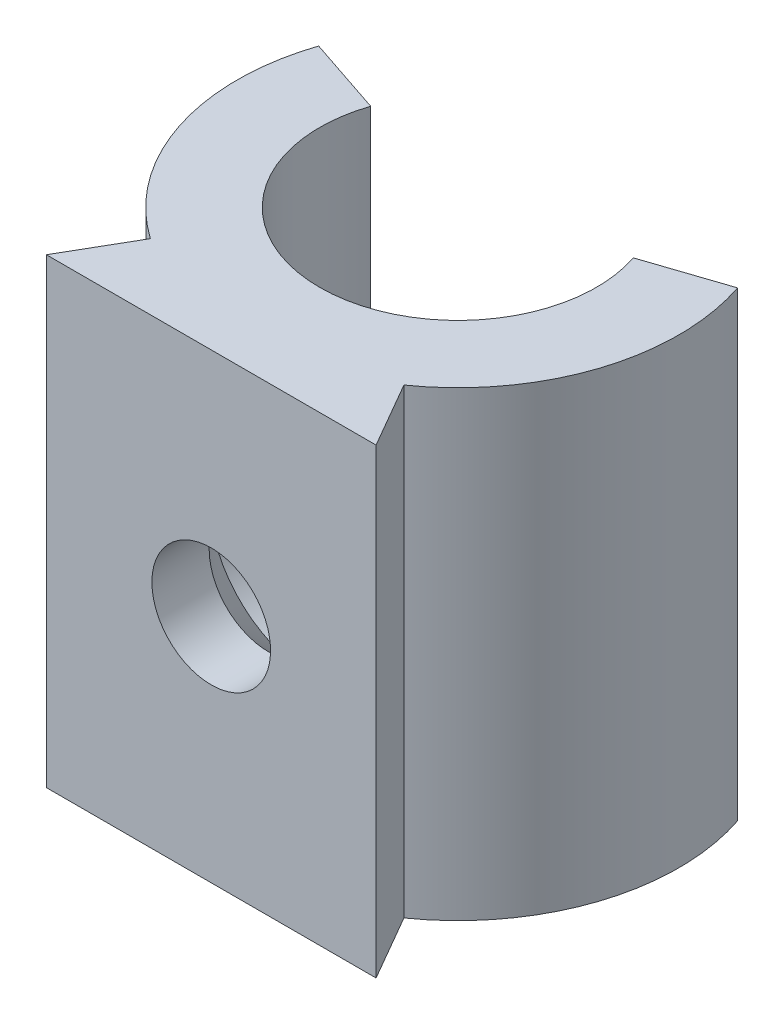
from build123d import *

# Parameters (mm, degrees)
BOSS_EXTRUDE1_DEPTH                             = 14
CUT_EXTRUDE1_DEPTH                              = 17.760296299
CUT_EXTRUDE1_DEPTH_BACK                         = 0.2
SKETCH4_R                                       = 3.25
CSK_FOR_M3_FLAT_HEAD_MACHINE_SCREW4_D           = 3.6
CSK_FOR_M3_FLAT_HEAD_MACHINE_SCREW4_DEPTH       = 7.5
CSK_FOR_M3_FLAT_HEAD_MACHINE_SCREW4_CSINK_D     = 6.3
CSK_FOR_M3_FLAT_HEAD_MACHINE_SCREW4_CSINK_ANGLE = 90
CSK_FOR_M3_FLAT_HEAD_MACHINE_SCREW4_TIP         = 1.081549114


with BuildPart() as part:
    # Sketch1 → Boss-Extrude1 (new body)
    with BuildSketch(Plane(origin=(0, 0, 0), x_dir=(1, 0, 0), z_dir=(0, 1, 0))):
        with BuildLine():
            Line((-5, -7.486681333), (5, -7.486681333))
            Line((5, -7.486681333), (3.845299462, -5.486681333))
            ThreePointArc((3.845299462, -5.486681333), (6.363430853, -2.096842336), (6.35376849, 2.125941198))
            Line((6.35376849, 2.125941198), (3.982959352, 1.332679557))
            ThreePointArc((3.982959352, 1.332679557), (0, -4.2), (-3.982959352, 1.332679557))
            Line((-3.982959352, 1.332679557), (-6.35376849, 2.125941198))
            ThreePointArc((-6.35376849, 2.125941198), (-6.363430853, -2.096842336), (-3.845299462, -5.486681333))
            Line((-3.845299462, -5.486681333), (-5, -7.486681333))
        make_face()
    extrude(amount=BOSS_EXTRUDE1_DEPTH)

    # Sketch4 → Cut-Extrude1 (cut, two sides: drawn at the far end of the back side and taken through both)
    with BuildSketch(Plane(origin=(0, 0, 4.2), x_dir=(-1, 0, 0), z_dir=(0, 0, -1)).offset(-CUT_EXTRUDE1_DEPTH_BACK)):
        with Locations((0, 7)):
            Circle(SKETCH4_R)
    extrude(amount=CUT_EXTRUDE1_DEPTH + CUT_EXTRUDE1_DEPTH_BACK, mode=Mode.SUBTRACT)

    # CSK for M3 Flat Head Machine Screw4
    with Locations(Plane(origin=(0, 0, 4.4), x_dir=(-1, 0, 0), z_dir=(0, 0, -1))):
        with Locations((0, 7)):
            CounterSinkHole(CSK_FOR_M3_FLAT_HEAD_MACHINE_SCREW4_D / 2, CSK_FOR_M3_FLAT_HEAD_MACHINE_SCREW4_CSINK_D / 2, depth=CSK_FOR_M3_FLAT_HEAD_MACHINE_SCREW4_DEPTH, counter_sink_angle=CSK_FOR_M3_FLAT_HEAD_MACHINE_SCREW4_CSINK_ANGLE)
            with Locations((0, 0, -(CSK_FOR_M3_FLAT_HEAD_MACHINE_SCREW4_DEPTH + CSK_FOR_M3_FLAT_HEAD_MACHINE_SCREW4_TIP / 2))):  # 118° drill point
                Cone(0, CSK_FOR_M3_FLAT_HEAD_MACHINE_SCREW4_D / 2, CSK_FOR_M3_FLAT_HEAD_MACHINE_SCREW4_TIP, mode=Mode.SUBTRACT)


solid = part.part
